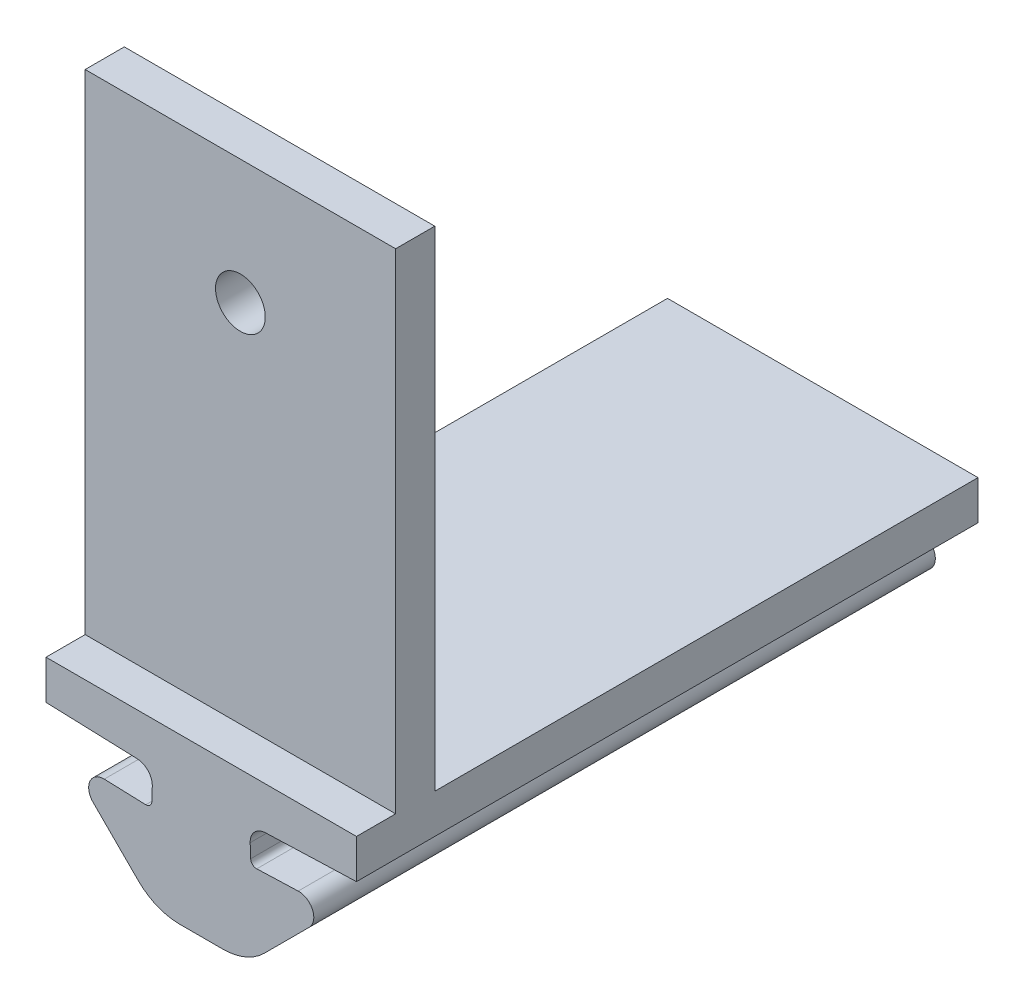
from build123d import *

# Parameters (mm, degrees)
BOSS_EXTRUDE1_DEPTH = 31.75
SKETCH19_W          = 15.860402013
SKETCH19_H          = 31.75
BOSS_EXTRUDE7_DEPTH = 2
SKETCH23_W          = 15.860402013
SKETCH23_H          = 2
BOSS_EXTRUDE8_DEPTH = 25
SKETCH24_R          = 1.27
CUT_EXTRUDE1_DEPTH  = 2.54


with BuildPart() as part:
    # Sketch2 → Boss-Extrude1 (new body)
    with BuildSketch(Plane.XY):
        with BuildLine():
            Line((-50.375618534, 45.609862895), (-50.351188886, 46.309436474))
            ThreePointArc((-50.351188886, 46.309436474), (-50.565618587, 46.88295476), (-51.12278195, 47.136868733))
            Line((-51.12278195, 47.136868733), (-55.780902554, 47.299533889))
            Line((-55.780902554, 47.299533889), (-47.850701548, 47.299533889))
            Line((-47.850701548, 47.299533889), (-47.850701548, 40.900752235))
            Line((-47.850701548, 40.900752235), (-48.952946324, 40.900752235))
            ThreePointArc((-48.952946324, 40.900752235), (-50.100996621, 41.129113637), (-51.074266668, 41.779431891))
            Line((-51.074266668, 41.779431891), (-53.375146928, 44.080312152))
            ThreePointArc((-53.375146928, 44.080312152), (-53.536830204, 44.931922499), (-52.803734096, 45.394471696))
            Line((-52.803734096, 45.394471696), (-50.685905631, 45.320515496))
            ThreePointArc((-50.685905631, 45.320515496), (-50.470836274, 45.400926634), (-50.375618534, 45.609862895))
        make_face()
    boss_extrude1 = extrude(amount=BOSS_EXTRUDE1_DEPTH)

    # Mirror2: Boss-Extrude1 across plane
    add(boss_extrude1.mirror(Plane(origin=(-47.850701548, 40.900752235, 31.75), x_dir=(0, 0, 1), z_dir=(-1, 0, 0))))

    # Sketch19 → Boss-Extrude7 (add)
    with BuildSketch(Plane(origin=(0, 47.299533889, 0), x_dir=(1, 0, 0), z_dir=(0, 1, 0))):
        with Locations((-47.850701548, -15.875)):
            Rectangle(SKETCH19_W, SKETCH19_H)
    extrude(amount=BOSS_EXTRUDE7_DEPTH)

    # Sketch23 → Boss-Extrude8 (add)
    with BuildSketch(Plane(origin=(0, 49.299533889, 0), x_dir=(1, 0, 0), z_dir=(0, 1, 0))):
        with Locations((-47.850701548, -28.75)):
            Rectangle(SKETCH23_W, SKETCH23_H)
    extrude(amount=BOSS_EXTRUDE8_DEPTH)

    # Sketch24 → Cut-Extrude1 (cut)
    with BuildSketch(Plane(origin=(0, 0, 27.75), x_dir=(-1, 0, 0), z_dir=(0, 0, -1))):
        with Locations((47.850701548, 67.949533889)):
            Circle(SKETCH24_R)
    extrude(amount=-CUT_EXTRUDE1_DEPTH, mode=Mode.SUBTRACT)


solid = part.part
